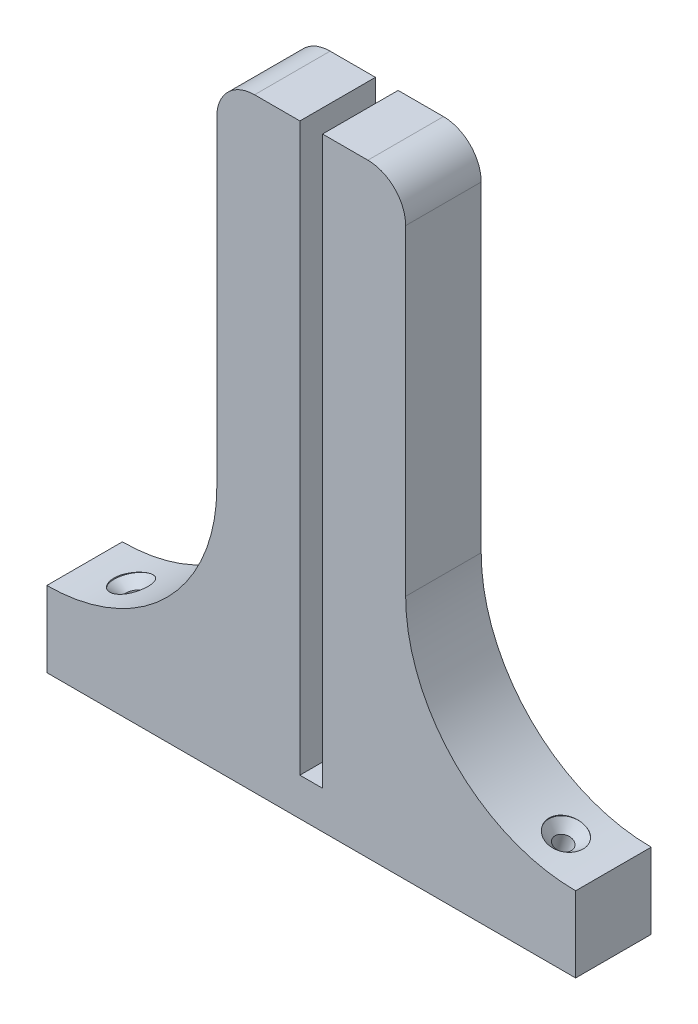
from build123d import *

# Parameters (mm, degrees)
BOSS_EXTRU_1_DEPTH                             = 20
CONG_1_R                                       = 10
ESQUISSE2_W                                    = 6
ESQUISSE2_H                                    = 150
ENL_V_MAT_EXTRU_1_DEPTH                        = 20
ENL_V_MAT_EXTRU_2_DEPTH                        = 0.6
FRAISAGE_POUR_VIS_T_TE_FRAIS_E_M41_D           = 4.5
FRAISAGE_POUR_VIS_T_TE_FRAIS_E_M41_CSINK_D     = 9.4
FRAISAGE_POUR_VIS_T_TE_FRAIS_E_M41_CSINK_ANGLE = 90


with BuildPart() as part:
    # Esquisse1 → Boss.-Extru.1 (new body)
    with BuildSketch(Plane.XY):
        with BuildLine():
            Line((-70, 0), (70, 0))
            Line((70, 0), (70, 20))
            ThreePointArc((70, 20), (38.180194847, 33.180194847), (25, 65))
            Line((25, 65), (25, 160))
            Line((25, 160), (-25, 160))
            Line((-25, 160), (-25, 65))
            ThreePointArc((-25, 65), (-38.180194847, 33.180194847), (-70, 20))
            Line((-70, 20), (-70, 0))
        make_face()
    extrude(amount=BOSS_EXTRU_1_DEPTH)

    # Congé1
    cong_1_edges = [part.edges().sort_by_distance(p)[0] for p in [
        (-25, 160, 10),
        (25, 160, 10),
    ]]
    fillet(cong_1_edges, radius=CONG_1_R)

    # Esquisse2 → Enlèv. mat.-Extru.1 (cut)
    with BuildSketch(Plane.XY.offset(20)):
        with Locations((0, 85)):
            Rectangle(ESQUISSE2_W, ESQUISSE2_H)
    extrude(amount=-ENL_V_MAT_EXTRU_1_DEPTH, mode=Mode.SUBTRACT)

    # Esquisse3 → Enlèv. mat.-Extru.2 (cut)
    with BuildSketch(Plane.ZY.offset(25)):
        with BuildLine():
            add(Edge.make_bspline(
                [(10.298264208, 116.00253619), (10.269097337, 115.992326869), (10.217774636, 115.974362311), (10.146223156, 115.960911494), (10.087850074, 115.966864128), (10.042769968, 115.997389601), (10.018320339, 116.051964444), (10.004954592, 116.125720815), (10.002334597, 116.224587194), (10.000840513, 116.299040881), (10, 116.340925628)],
                knots=[0, 0, 0, 0, 9.2636e-05, 0.000163005, 0.000217104, 0.000264221, 0.000318666, 0.000391065, 0.000488849, 0.000614604, 0.000614604, 0.000614604, 0.000614604], degree=3))
            add(Edge.make_bspline(
                [(10, 116.340925628), (10.000114375, 116.382830885), (10.000317702, 116.45732656), (10.004773603, 116.556579531), (10.01453085, 116.631507153), (10.02464009, 116.687809902), (10.043786522, 116.728119067), (10.070404737, 116.755826472), (10.102576181, 116.775404191), (10.125641709, 116.786940542), (10.137763289, 116.793003217)],
                knots=[0, 0, 0, 0, 0.000125733, 0.000223517, 0.000297674, 0.000352512, 0.000394382, 0.000429388, 0.000466115, 0.000506793, 0.000506793, 0.000506793, 0.000506793], degree=3))
            Line((10.137763289, 116.793003217), (11.540808824, 117.293231081))
            Line((11.540808824, 117.293231081), (11.540808824, 119.722144991))
            Line((11.540808824, 119.722144991), (10.156488396, 120.200972733))
            add(Edge.make_bspline(
                [(10.156488396, 120.200972733), (10.143862376, 120.205976287), (10.119506065, 120.215628427), (10.085507972, 120.235820612), (10.058092353, 120.265723983), (10.033968103, 120.305141208), (10.017547599, 120.359621157), (10.005565685, 120.430956204), (10.002174093, 120.522853414), (10.00077614, 120.591090262), (10, 120.628975184)],
                knots=[0, 0, 0, 0, 4.0745e-05, 7.8599e-05, 0.000117386, 0.000161199, 0.000216183, 0.000286768, 0.000377875, 0.000491595, 0.000491595, 0.000491595, 0.000491595], degree=3))
            add(Edge.make_bspline(
                [(10, 120.628975184), (10.000510946, 120.66864451), (10.00143085, 120.740064936), (10.007654826, 120.836367622), (10.023164734, 120.908664456), (10.048583816, 120.962231124), (10.093140982, 120.990826296), (10.15073614, 120.995142921), (10.221785969, 120.982308262), (10.273109429, 120.964251351), (10.302276731, 120.953989545)],
                knots=[0, 0, 0, 0, 0.000119068, 0.00021437, 0.000288659, 0.000340753, 0.000387124, 0.000439714, 0.000510082, 0.000602719, 0.000602719, 0.000602719, 0.000602719], degree=3))
            Line((10.302276731, 120.953989545), (15.665682445, 118.995878332))
            add(Edge.make_bspline(
                [(15.665682445, 118.995878332), (15.680224312, 118.989272066), (15.708098977, 118.976608806), (15.745112383, 118.949084074), (15.773356627, 118.910133289), (15.792627136, 118.858485618), (15.806954153, 118.793229828), (15.815447144, 118.711183525), (15.820619559, 118.609856356), (15.820757428, 118.53533922), (15.820833333, 118.49431296)],
                knots=[0, 0, 0, 0, 4.7852e-05, 9.1726e-05, 0.000136667, 0.000190067, 0.000255931, 0.000336726, 0.000437182, 0.00056024, 0.00056024, 0.00056024, 0.00056024], degree=3))
            add(Edge.make_bspline(
                [(15.820833333, 118.49431296), (15.820751345, 118.450170997), (15.820603023, 118.370316023), (15.815545051, 118.261812307), (15.806709356, 118.174582224), (15.793508021, 118.105178335), (15.771516131, 118.051537529), (15.742893381, 118.010273306), (15.7043801, 117.981144433), (15.675352025, 117.968518025), (15.660332414, 117.961984911)],
                knots=[0, 0, 0, 0, 0.00013242, 0.000239554, 0.000325665, 0.000395447, 0.000450594, 0.000498483, 0.000544233, 0.000593285, 0.000593285, 0.000593285, 0.000593285], degree=3))
            Line((15.660332414, 117.961984911), (10.298264208, 116.00253619))
        make_face()
        Polygon((15.050428922, 118.51705059), (15.050428922, 118.521063113), (12.140012255, 119.52820638), (12.140012255, 117.496532246), align=None, mode=Mode.SUBTRACT)
        with BuildLine():
            add(Edge.make_bspline(
                [(10.137763289, 114.305238971), (10.126952741, 114.306440051), (10.105807787, 114.308789312), (10.075590027, 114.322520282), (10.052152964, 114.34960007), (10.031346744, 114.386960575), (10.01867842, 114.439438389), (10.005169697, 114.506555801), (10.002316192, 114.59327153), (10.000826824, 114.657474067), (10, 114.693116192)],
                knots=[0, 0, 0, 0, 3.2543e-05, 6.3653e-05, 9.6768e-05, 0.000138079, 0.000190991, 0.000257625, 0.000343393, 0.000450427, 0.000450427, 0.000450427, 0.000450427], degree=3))
            add(Edge.make_bspline(
                [(10, 114.693116192), (10.000788929, 114.727430941), (10.002214206, 114.789423857), (10.005533098, 114.874244869), (10.018513727, 114.941543918), (10.031979891, 114.995265081), (10.050944416, 115.034754777), (10.075826673, 115.061160417), (10.105990396, 115.073434551), (10.12697314, 115.074893258), (10.137763289, 115.075643382)],
                knots=[0, 0, 0, 0, 0.000103023, 0.000186121, 0.000254071, 0.000308269, 0.000351938, 0.000384094, 0.000414652, 0.000447002, 0.000447002, 0.000447002, 0.000447002], degree=3))
            Line((10.137763289, 115.075643382), (14.142261221, 115.075643382))
            add(Edge.make_bspline(
                [(14.142261221, 115.075643382), (14.153100676, 115.074988992), (14.173768968, 115.073741223), (14.203196443, 115.060372601), (14.229274794, 115.035150123), (14.248947591, 114.995108055), (14.267208843, 114.942366519), (14.274209332, 114.873798524), (14.279977411, 114.789543787), (14.28000773, 114.727471176), (14.28002451, 114.693116192)],
                knots=[0, 0, 0, 0, 3.235e-05, 6.1684e-05, 9.4799e-05, 0.000139099, 0.000194083, 0.000261611, 0.000344708, 0.000447705, 0.000447705, 0.000447705, 0.000447705], degree=3))
            add(Edge.make_bspline(
                [(14.28002451, 114.693116192), (14.279987354, 114.657430062), (14.279920417, 114.593141559), (14.274485048, 114.507027011), (14.267034375, 114.438605055), (14.249618683, 114.387078279), (14.22805071, 114.349271182), (14.203376024, 114.323332935), (14.173976891, 114.30846141), (14.153126405, 114.306342917), (14.142261221, 114.305238971)],
                knots=[0, 0, 0, 0, 0.000107009, 0.000192776, 0.00025898, 0.000312697, 0.000354674, 0.000388722, 0.000418629, 0.000451172, 0.000451172, 0.000451172, 0.000451172], degree=3))
            Line((14.142261221, 114.305238971), (10.137763289, 114.305238971))
        make_face()
        with BuildLine():
            add(Edge.make_bspline(
                [(15.482443896, 114.904442402), (15.444864984, 114.90497412), (15.374947984, 114.905963402), (15.280152438, 114.925297195), (15.201582572, 114.951540877), (15.141020965, 114.995603849), (15.097897588, 115.056740729), (15.07119576, 115.13545123), (15.051978121, 115.230315707), (15.050970498, 115.300221823), (15.050428922, 115.337794884)],
                knots=[0, 0, 0, 0, 0.000112478, 0.00020927, 0.000289263, 0.000359083, 0.000429984, 0.000509977, 0.000606769, 0.000719247, 0.000719247, 0.000719247, 0.000719247], degree=3))
            add(Edge.make_bspline(
                [(15.050428922, 115.337794884), (15.051042843, 115.375350428), (15.052169349, 115.444262387), (15.07001531, 115.537842549), (15.095166142, 115.613961669), (15.135593008, 115.674019365), (15.195496519, 115.713766754), (15.270349855, 115.741646957), (15.363585716, 115.758385572), (15.431991775, 115.75972261), (15.469068819, 115.760447304)],
                knots=[0, 0, 0, 0, 0.000112478, 0.00020639, 0.000284665, 0.000351834, 0.000419003, 0.000496498, 0.00059041, 0.000701552, 0.000701552, 0.000701552, 0.000701552], degree=3))
            add(Edge.make_bspline(
                [(15.469068819, 115.760447304), (15.507481007, 115.759692066), (15.57853694, 115.758295007), (15.675854588, 115.741758824), (15.754269606, 115.713153879), (15.815387889, 115.671002169), (15.85937987, 115.611497135), (15.887461278, 115.534260122), (15.904379597, 115.439291858), (15.905712187, 115.369979507), (15.906433824, 115.332444853)],
                knots=[0, 0, 0, 0, 0.00011515, 0.000213008, 0.000294727, 0.000363761, 0.00043251, 0.000512983, 0.000608209, 0.000720687, 0.000720687, 0.000720687, 0.000720687], degree=3))
            add(Edge.make_bspline(
                [(15.906433824, 115.332444853), (15.905746572, 115.294903577), (15.904477479, 115.225578998), (15.887188017, 115.130845605), (15.86034961, 115.053432876), (15.818635727, 114.992794954), (15.758906922, 114.950494476), (15.68232171, 114.923479461), (15.588403853, 114.906519168), (15.519534335, 114.905169357), (15.482443896, 114.904442402)],
                knots=[0, 0, 0, 0, 0.000112478, 0.000207704, 0.000287698, 0.000356732, 0.000424682, 0.000503425, 0.000598651, 0.000709793, 0.000709793, 0.000709793, 0.000709793], degree=3))
        make_face()
        with BuildLine():
            add(Edge.make_bspline(
                [(15.482443896, 113.449234069), (15.444864984, 113.449765787), (15.374947984, 113.450755069), (15.280152438, 113.470088862), (15.201582572, 113.496332543), (15.141020965, 113.540395515), (15.097897588, 113.601532395), (15.07119576, 113.680242896), (15.051978121, 113.775107374), (15.050970498, 113.845013489), (15.050428922, 113.88258655)],
                knots=[0, 0, 0, 0, 0.000112478, 0.00020927, 0.000289263, 0.000359083, 0.000429984, 0.000509977, 0.000606769, 0.000719247, 0.000719247, 0.000719247, 0.000719247], degree=3))
            add(Edge.make_bspline(
                [(15.050428922, 113.88258655), (15.051042843, 113.920142095), (15.052169349, 113.989054054), (15.07001531, 114.082634216), (15.095166142, 114.158753336), (15.135593008, 114.218811032), (15.195496519, 114.258558421), (15.270349855, 114.286438624), (15.363585716, 114.303177238), (15.431991775, 114.304514277), (15.469068819, 114.305238971)],
                knots=[0, 0, 0, 0, 0.000112478, 0.00020639, 0.000284665, 0.000351834, 0.000419003, 0.000496498, 0.00059041, 0.000701552, 0.000701552, 0.000701552, 0.000701552], degree=3))
            add(Edge.make_bspline(
                [(15.469068819, 114.305238971), (15.507480723, 114.304483612), (15.578536131, 114.303086328), (15.675857083, 114.286551557), (15.75426241, 114.257942471), (15.815410243, 114.21580339), (15.85904033, 114.156589791), (15.887356633, 114.08087932), (15.904497657, 113.987675081), (15.905750426, 113.919679053), (15.906433824, 113.88258655)],
                knots=[0, 0, 0, 0, 0.00011515, 0.000213008, 0.000294727, 0.000363761, 0.00043251, 0.000511739, 0.000604337, 0.000715479, 0.000715479, 0.000715479, 0.000715479], degree=3))
            add(Edge.make_bspline(
                [(15.906433824, 113.88258655), (15.905777513, 113.844148176), (15.904570951, 113.773483077), (15.887088424, 113.67705046), (15.86068409, 113.598539584), (15.818612961, 113.537595226), (15.758914017, 113.495283461), (15.682319241, 113.468272061), (15.588404648, 113.451310534), (15.519534614, 113.449960919), (15.482443896, 113.449234069)],
                knots=[0, 0, 0, 0, 0.00011515, 0.000211692, 0.000292939, 0.000361973, 0.000429923, 0.000508666, 0.000603892, 0.000715034, 0.000715034, 0.000715034, 0.000715034], degree=3))
        make_face()
        with BuildLine():
            add(Edge.make_bspline(
                [(12.295163143, 109.426011029), (12.267907447, 109.426947638), (12.216857846, 109.428701896), (12.145758019, 109.443741511), (12.088029732, 109.472661135), (12.042032764, 109.510528174), (12.011185902, 109.557494869), (11.985689828, 109.60534849), (11.972530905, 109.657632034), (11.970060534, 109.693009755), (11.968811275, 109.710900161)],
                knots=[0, 0, 0, 0, 8.1763e-05, 0.000153142, 0.000215947, 0.000273832, 0.000329496, 0.000383329, 0.000435885, 0.000489652, 0.000489652, 0.000489652, 0.000489652], degree=3))
            Line((11.968811275, 109.710900161), (11.968811275, 112.336427696))
            add(Edge.make_bspline(
                [(11.968811275, 112.336427696), (11.914399597, 112.335675361), (11.808556941, 112.334211905), (11.653481631, 112.322310073), (11.507008251, 112.300871807), (11.368645965, 112.271985648), (11.239466638, 112.233398202), (11.119292521, 112.184116643), (11.009201712, 112.122029714), (10.908363832, 112.049779916), (10.817107913, 111.966109096), (10.738576645, 111.869012352), (10.669739472, 111.760988947), (10.611688096, 111.641502327), (10.567739016, 111.508291514), (10.535853566, 111.362218198), (10.517464709, 111.202241204), (10.514921785, 111.091255885), (10.513602941, 111.033695236)],
                knots=[0, 0, 0, 0, 0.000163225, 0.000317509, 0.000466183, 0.000607054, 0.000741185, 0.0008701, 0.000995855, 0.001119464, 0.001241558, 0.001366062, 0.001492956, 0.00162516, 0.001763467, 0.001912748, 0.002073009, 0.002245677, 0.002245677, 0.002245677, 0.002245677], degree=3))
            add(Edge.make_bspline(
                [(10.513602941, 111.033695236), (10.513800845, 110.987296925), (10.514183925, 110.897484363), (10.526135339, 110.766802361), (10.541089055, 110.643807458), (10.571341734, 110.494681598), (10.617109769, 110.327080018), (10.679127929, 110.149631539), (10.743769883, 110.003142849), (10.796377529, 109.884546936), (10.844080672, 109.795758508), (10.852556206, 109.740196061), (10.856004902, 109.717587699)],
                knots=[0, 0, 0, 0, 0.000139127, 0.000269305, 0.000393398, 0.00051065, 0.000725439, 0.000914109, 0.001074102, 0.001205164, 0.001304572, 0.001372772, 0.001372772, 0.001372772, 0.001372772], degree=3))
            add(Edge.make_bspline(
                [(10.856004902, 109.717587699), (10.85525752, 109.707644375), (10.853771909, 109.687879486), (10.841206037, 109.660963629), (10.821469304, 109.637618619), (10.791286215, 109.622066765), (10.752471041, 109.609904542), (10.702367706, 109.603044318), (10.640357119, 109.59729763), (10.594767264, 109.597242324), (10.569778263, 109.59721201)],
                knots=[0, 0, 0, 0, 2.9697e-05, 5.9031e-05, 8.7467e-05, 0.000119817, 0.000159154, 0.000209289, 0.000271046, 0.000345959, 0.000345959, 0.000345959, 0.000345959], degree=3))
            add(Edge.make_bspline(
                [(10.569778263, 109.59721201), (10.551946828, 109.597591463), (10.518492316, 109.598303375), (10.47152045, 109.600285917), (10.430548176, 109.606216175), (10.394179233, 109.612436835), (10.36157064, 109.621504073), (10.331991032, 109.635324997), (10.306175037, 109.654828734), (10.282092858, 109.672925032), (10.263408262, 109.697957154), (10.244853866, 109.729608512), (10.22161801, 109.773336712), (10.178353861, 109.851181111), (10.127168962, 109.976012971), (10.065204935, 110.152307677), (10.009219881, 110.363008798), (9.958570297, 110.602729633), (9.920487255, 110.866695606), (9.91646252, 111.050495646), (9.91439951, 111.144708372)],
                knots=[0, 0, 0, 0, 5.3517e-05, 0.000100406, 0.000140886, 0.000177613, 0.000211051, 0.000242161, 0.000274813, 0.000308036, 0.00033185, 0.000367863, 0.00041814, 0.000480374, 0.000634924, 0.000821888, 0.001040901, 0.001288267, 0.00155687, 0.001839341, 0.001839341, 0.001839341, 0.001839341], degree=3))
            add(Edge.make_bspline(
                [(9.91439951, 111.144708372), (9.91638233, 111.226347584), (9.92023875, 111.385129062), (9.944655805, 111.615454988), (9.989788218, 111.82949561), (10.048389302, 112.028955847), (10.12911499, 112.21185356), (10.222624563, 112.381602309), (10.337368019, 112.53369645), (10.465595834, 112.672861088), (10.612864486, 112.795181561), (10.777303394, 112.901331926), (10.959182186, 112.991053501), (11.158305419, 113.064462021), (11.374658359, 113.121723471), (11.608227466, 113.16246028), (11.858544913, 113.188537691), (12.031160515, 113.191109648), (12.11994964, 113.192432598)],
                knots=[0, 0, 0, 0, 0.000244943, 0.000476394, 0.000693589, 0.000900488, 0.001098769, 0.001292209, 0.001480532, 0.001668855, 0.001858771, 0.002053171, 0.002254748, 0.002465926, 0.002688813, 0.002925204, 0.003176606, 0.003442891, 0.003442891, 0.003442891, 0.003442891], degree=3))
            add(Edge.make_bspline(
                [(12.11994964, 113.192432598), (12.204727247, 113.191081829), (12.37022644, 113.188444915), (12.612156171, 113.162334556), (12.840943919, 113.120411618), (13.056162214, 113.059923826), (13.256361416, 112.983622524), (13.443411775, 112.894433583), (13.612747004, 112.787093882), (13.767028533, 112.666129303), (13.903758047, 112.530121507), (14.025498183, 112.381082084), (14.128228477, 112.217097921), (14.214099247, 112.0408566), (14.282949083, 111.853302294), (14.330244129, 111.653935337), (14.360943881, 111.444373846), (14.364043412, 111.300862803), (14.365625, 111.227633847)],
                knots=[0, 0, 0, 0, 0.000254253, 0.000496342, 0.000729026, 0.00095133, 0.001165953, 0.001371133, 0.001571889, 0.001766154, 0.001958146, 0.002149279, 0.002342237, 0.002537243, 0.002736531, 0.002940255, 0.00315097, 0.003370521, 0.003370521, 0.003370521, 0.003370521], degree=3))
            add(Edge.make_bspline(
                [(14.365625, 111.227633847), (14.36413248, 111.149942936), (14.361255734, 111.000198224), (14.330750997, 110.784800258), (14.284335776, 110.586701434), (14.214390198, 110.407787782), (14.131479226, 110.244328144), (14.033546255, 110.097075415), (13.922618452, 109.963993944), (13.798329619, 109.846265723), (13.660853272, 109.744369144), (13.512322767, 109.656821694), (13.352867777, 109.583223786), (13.18254065, 109.524345579), (13.003504556, 109.481518154), (12.818225456, 109.44875662), (12.626799801, 109.430159793), (12.497164695, 109.427404693), (12.431588925, 109.426011029)],
                knots=[0, 0, 0, 0, 0.000232915, 0.000448929, 0.000651353, 0.000841872, 0.001023719, 0.001200295, 0.001371203, 0.001542451, 0.001712583, 0.001883475, 0.002058816, 0.002238586, 0.002423166, 0.002610513, 0.002802691, 0.002999418, 0.002999418, 0.002999418, 0.002999418], degree=3))
            Line((12.431588925, 109.426011029), (12.295163143, 109.426011029))
        make_face()
        with BuildLine():
            add(Edge.make_bspline(
                [(12.482414216, 110.196415441), (12.531018437, 110.196304615), (12.625655426, 110.196088825), (12.763857224, 110.205028113), (12.894201906, 110.224340943), (13.01680672, 110.249670581), (13.130470878, 110.287036267), (13.236778829, 110.33035765), (13.334490566, 110.384510528), (13.425075572, 110.445615915), (13.504882091, 110.516765197), (13.575998123, 110.594940329), (13.634821343, 110.682615941), (13.682924577, 110.777981399), (13.721041532, 110.881102693), (13.747051665, 110.992072512), (13.763688977, 111.111215197), (13.765490234, 111.193245426), (13.766421569, 111.235658892)],
                knots=[0, 0, 0, 0, 0.000145794, 0.000283876, 0.000414958, 0.000540883, 0.000658895, 0.000773406, 0.000884741, 0.000993442, 0.001100518, 0.001204706, 0.00130969, 0.001416162, 0.001524492, 0.001638683, 0.001757473, 0.001884648, 0.001884648, 0.001884648, 0.001884648], degree=3))
            add(Edge.make_bspline(
                [(13.766421569, 111.235658892), (13.765198304, 111.27898316), (13.762813496, 111.363445694), (13.742546762, 111.485696501), (13.70876393, 111.599777618), (13.662171493, 111.705331458), (13.603182488, 111.801778684), (13.539042617, 111.892291699), (13.462134345, 111.971266878), (13.379437206, 112.043993531), (13.287924301, 112.108512814), (13.188323525, 112.164022393), (13.082645531, 112.214757632), (12.93017424, 112.266353778), (12.730771119, 112.318950187), (12.565736164, 112.330564118), (12.482414216, 112.336427696)],
                knots=[0, 0, 0, 0, 0.00012991, 0.000253266, 0.000370487, 0.000486056, 0.000598223, 0.000709244, 0.000818044, 0.000928013, 0.00103934, 0.001153146, 0.001269824, 0.001390385, 0.001635627, 0.001885698, 0.001885698, 0.001885698, 0.001885698], degree=3))
            Line((12.482414216, 112.336427696), (12.482414216, 110.196415441))
        make_face(mode=Mode.SUBTRACT)
        with BuildLine():
            add(Edge.make_bspline(
                [(10.345076976, 103.177175245), (10.317000076, 103.177956538), (10.26524768, 103.179396647), (10.193775132, 103.182931754), (10.134591551, 103.195525879), (10.085769193, 103.212028557), (10.047624521, 103.234975624), (10.01854723, 103.261914966), (10.003103851, 103.296652865), (10.001058104, 103.321046651), (10, 103.333663641)],
                knots=[0, 0, 0, 0, 8.4305e-05, 0.000155395, 0.000214154, 0.000265348, 0.00030916, 0.00034699, 0.000382301, 0.000420132, 0.000420132, 0.000420132, 0.000420132], degree=3))
            Line((10, 103.333663641), (10, 105.886965763))
            add(Edge.make_bspline(
                [(10, 105.886965763), (10.003536552, 105.92100722), (10.010796097, 105.990884735), (10.05650501, 106.070315548), (10.110312551, 106.124438375), (10.167185469, 106.153632745), (10.236145728, 106.171130851), (10.286104631, 106.172471361), (10.312976792, 106.173192402)],
                knots=[0, 0, 0, 0, 0.000101809, 0.000208985, 0.000266684, 0.000328918, 0.000398016, 0.000478445, 0.000478445, 0.000478445, 0.000478445], degree=3))
            Line((10.312976792, 106.173192402), (15.677720014, 106.173192402))
            add(Edge.make_bspline(
                [(15.677720014, 106.173192402), (15.689023202, 106.17209402), (15.711307587, 106.169928546), (15.742781873, 106.154303145), (15.768860774, 106.124764877), (15.784104611, 106.078986859), (15.79899446, 106.019613199), (15.809880164, 105.943369105), (15.820346784, 105.85023515), (15.820661732, 105.782238359), (15.820833333, 105.745189951)],
                knots=[0, 0, 0, 0, 3.3863e-05, 6.6761e-05, 0.00010275, 0.000148947, 0.000209609, 0.000286791, 0.000379553, 0.000490598, 0.000490598, 0.000490598, 0.000490598], degree=3))
            add(Edge.make_bspline(
                [(15.820833333, 105.745189951), (15.820642524, 105.707256606), (15.820293837, 105.637936914), (15.810280107, 105.544260201), (15.798759146, 105.469062327), (15.784401262, 105.411174422), (15.768039609, 105.366641961), (15.743291519, 105.336067331), (15.711257974, 105.320491248), (15.689006506, 105.318299307), (15.677720014, 105.3171875)],
                knots=[0, 0, 0, 0, 0.00011372, 0.000207812, 0.000282353, 0.000341718, 0.000386679, 0.000423673, 0.000456571, 0.000490434, 0.000490434, 0.000490434, 0.000490434], degree=3))
            Line((15.677720014, 105.3171875), (10.684803922, 105.3171875))
            Line((10.684803922, 105.3171875), (10.684803922, 103.326976103))
            add(Edge.make_bspline(
                [(10.684803922, 103.326976103), (10.683906626, 103.314703221), (10.682156495, 103.290765577), (10.664462281, 103.259065487), (10.638945237, 103.232111236), (10.602922544, 103.210734794), (10.55551668, 103.195231414), (10.496790857, 103.183056829), (10.42491444, 103.179362967), (10.373156749, 103.177944692), (10.345076976, 103.177175245)],
                knots=[0, 0, 0, 0, 3.6507e-05, 7.1205e-05, 0.000106211, 0.000147043, 0.000195268, 0.000255336, 0.000326426, 0.000410731, 0.000410731, 0.000410731, 0.000410731], degree=3))
        make_face()
        with BuildLine():
            add(Edge.make_bspline(
                [(10.133750766, 99.325153186), (10.117499868, 99.326553216), (10.086383753, 99.329233897), (10.049341677, 99.362577538), (10.028311647, 99.410039503), (10.00951912, 99.471876554), (10.002560398, 99.556885748), (10.000934697, 99.621209577), (10, 99.658192593)],
                knots=[0, 0, 0, 0, 4.774e-05, 9.1409e-05, 0.000141059, 0.000202424, 0.000284548, 0.000395633, 0.000395633, 0.000395633, 0.000395633], degree=3))
            add(Edge.make_bspline(
                [(10, 99.658192593), (10.000909497, 99.695183669), (10.00251313, 99.760406658), (10.009972006, 99.847514115), (10.027422764, 99.911366001), (10.049025137, 99.960014596), (10.08840417, 99.98930887), (10.1190282, 99.991447797), (10.135088274, 99.992569508)],
                knots=[0, 0, 0, 0, 0.000111086, 0.000195867, 0.00026109, 0.000309555, 0.000352626, 0.000400122, 0.000400122, 0.000400122, 0.000400122], degree=3))
            Line((10.135088274, 99.992569508), (10.541690602, 99.992569508))
            add(Edge.make_bspline(
                [(10.541690602, 99.992569508), (10.495897809, 100.036864691), (10.405072698, 100.124719452), (10.283271821, 100.268410027), (10.176159904, 100.419853721), (10.083267964, 100.577692324), (10.007380833, 100.742027054), (9.954065325, 100.912838845), (9.920375564, 101.088446581), (9.916401679, 101.207321408), (9.91439951, 101.267214308)],
                knots=[0, 0, 0, 0, 0.000191044, 0.000378915, 0.000564096, 0.000746924, 0.000927685, 0.001105775, 0.001282589, 0.001462134, 0.001462134, 0.001462134, 0.001462134], degree=3))
            add(Edge.make_bspline(
                [(9.91439951, 101.267214308), (9.915360016, 101.318979135), (9.917244433, 101.42053657), (9.933916385, 101.568434669), (9.958770938, 101.709057671), (9.995249389, 101.841306575), (10.039927583, 101.96633699), (10.09645303, 102.081049106), (10.160842186, 102.186722498), (10.234936635, 102.282172152), (10.317844947, 102.36849119), (10.411146874, 102.443202853), (10.51180144, 102.509751141), (10.622090958, 102.564181662), (10.740593243, 102.6089689), (10.867562616, 102.640722636), (11.002563505, 102.659637652), (11.094911125, 102.662239219), (11.142231541, 102.663572304)],
                knots=[0, 0, 0, 0, 0.000155243, 0.000304572, 0.000445975, 0.000583224, 0.000715664, 0.000843674, 0.000966171, 0.001086294, 0.001205475, 0.001324333, 0.001444157, 0.001566778, 0.001692483, 0.001823538, 0.001958593, 0.002100527, 0.002100527, 0.002100527, 0.002100527], degree=3))
            add(Edge.make_bspline(
                [(11.142231541, 102.663572304), (11.197204299, 102.66238753), (11.304283877, 102.660079749), (11.458546266, 102.631913965), (11.602736212, 102.59017851), (11.734051929, 102.527179742), (11.856033261, 102.450861886), (11.966095099, 102.3574877), (12.065692549, 102.249638577), (12.154393656, 102.126946676), (12.23163765, 101.989188214), (12.300525564, 101.837909522), (12.355589863, 101.670679666), (12.402482611, 101.490698724), (12.437835007, 101.297031902), (12.465038532, 101.091776165), (12.479053921, 100.874183248), (12.481274858, 100.72554055), (12.482414216, 100.649285769)],
                knots=[0, 0, 0, 0, 0.000164709, 0.000320831, 0.000468927, 0.000613724, 0.000756211, 0.000899549, 0.001045307, 0.001195662, 0.001352601, 0.00151842, 0.001693526, 0.001880059, 0.002076016, 0.002283722, 0.002500898, 0.002729674, 0.002729674, 0.002729674, 0.002729674], degree=3))
            Line((12.482414216, 100.649285769), (12.482414216, 100.095557598))
            Line((12.482414216, 100.095557598), (12.800741039, 100.095557598))
            add(Edge.make_bspline(
                [(12.800741039, 100.095557598), (12.875415585, 100.097319938), (13.016467878, 100.10064881), (13.18557477, 100.134073572), (13.30698104, 100.170050909), (13.385927587, 100.20939981), (13.459778752, 100.251134174), (13.524264189, 100.304094664), (13.580349059, 100.365088831), (13.631293901, 100.432366258), (13.671574311, 100.509328771), (13.707834303, 100.593370663), (13.73327889, 100.68762342), (13.754253241, 100.791128017), (13.763786637, 100.905021202), (13.765521508, 100.984099258), (13.766421569, 101.025125421)],
                knots=[0, 0, 0, 0, 0.000223688, 0.000422523, 0.000515159, 0.000602508, 0.000686462, 0.000769182, 0.000851513, 0.000934707, 0.001021491, 0.001111413, 0.001208785, 0.001313709, 0.001427899, 0.001551015, 0.001551015, 0.001551015, 0.001551015], degree=3))
            add(Edge.make_bspline(
                [(13.766421569, 101.025125421), (13.765663343, 101.069734641), (13.764181904, 101.156893229), (13.752271143, 101.284380474), (13.731177843, 101.404733502), (13.691436583, 101.5514648), (13.636050132, 101.718685705), (13.556696724, 101.895835407), (13.482431302, 102.047645139), (13.419526462, 102.154560643), (13.376117406, 102.226595203), (13.357235982, 102.272590708), (13.34124856, 102.309889731), (13.339281268, 102.333542384), (13.338419118, 102.343907973)],
                knots=[0, 0, 0, 0, 0.000133811, 0.000261443, 0.000383706, 0.000499846, 0.000717248, 0.000911316, 0.001081789, 0.001223798, 0.001283688, 0.001333392, 0.001373159, 0.001404182, 0.001404182, 0.001404182, 0.001404182], degree=3))
            add(Edge.make_bspline(
                [(13.338419118, 102.343907973), (13.339605797, 102.35517395), (13.341925165, 102.377193338), (13.355925818, 102.408754956), (13.381429227, 102.433958361), (13.4154436, 102.456133285), (13.459009408, 102.474980387), (13.5138067, 102.483905141), (13.57586596, 102.490807356), (13.620159541, 102.491833559), (13.643370864, 102.492371324)],
                knots=[0, 0, 0, 0, 3.3863e-05, 6.6185e-05, 0.000101191, 0.000139771, 0.000187716, 0.000242276, 0.000305494, 0.000375096, 0.000375096, 0.000375096, 0.000375096], degree=3))
            add(Edge.make_bspline(
                [(13.643370864, 102.492371324), (13.678619999, 102.491700383), (13.741361652, 102.490506142), (13.828157635, 102.480045087), (13.903493282, 102.452401165), (13.954888143, 102.407163992), (13.997022102, 102.361116258), (14.027831305, 102.31151224), (14.063206547, 102.253464592), (14.109997414, 102.15664055), (14.17015264, 102.019646647), (14.22961154, 101.834543825), (14.285331192, 101.630530488), (14.327554847, 101.409672397), (14.361223841, 101.179035744), (14.364156208, 101.022129933), (14.365625, 100.943537454)],
                knots=[0, 0, 0, 0, 0.000105739, 0.00018821, 0.000261481, 0.00034232, 0.000390637, 0.000448507, 0.000516864, 0.000594623, 0.000770774, 0.000965334, 0.001177193, 0.001404876, 0.001639626, 0.001875214, 0.001875214, 0.001875214, 0.001875214], degree=3))
            add(Edge.make_bspline(
                [(14.365625, 100.943537454), (14.364124889, 100.872628844), (14.361233157, 100.735939879), (14.345286742, 100.538465714), (14.312473984, 100.358059004), (14.27063192, 100.193377129), (14.215342529, 100.045225642), (14.149635664, 99.911308844), (14.072622803, 99.791284188), (13.98135944, 99.687678056), (13.880843409, 99.596355169), (13.766052947, 99.521766878), (13.642201895, 99.456678172), (13.505066787, 99.407655671), (13.357541989, 99.370718206), (13.1983325, 99.344048681), (13.027555782, 99.328038598), (12.909560532, 99.326132987), (12.848891314, 99.325153186)],
                knots=[0, 0, 0, 0, 0.000212769, 0.00041015, 0.000593544, 0.00076224, 0.000919254, 0.001066998, 0.001209083, 0.0013456, 0.001480111, 0.00161514, 0.001755119, 0.001898987, 0.002050804, 0.002210881, 0.002382833, 0.002564812, 0.002564812, 0.002564812, 0.002564812], degree=3))
            Line((12.848891314, 99.325153186), (10.133750766, 99.325153186))
        make_face()
        with BuildLine():
            Line((11.968811275, 100.095557598), (11.968811275, 100.720173675))
            add(Edge.make_bspline(
                [(11.968811275, 100.720173675), (11.968615955, 100.768799729), (11.968239116, 100.862616467), (11.956412711, 100.998215786), (11.941498208, 101.12390065), (11.918280216, 101.239471808), (11.890531357, 101.346070197), (11.8563154, 101.443481175), (11.814772465, 101.531495295), (11.766172214, 101.608773592), (11.714174134, 101.678521548), (11.655280176, 101.737047841), (11.591580081, 101.786366968), (11.522630461, 101.824722362), (11.449539645, 101.856805981), (11.37044205, 101.87700566), (11.286323775, 101.891539898), (11.228347295, 101.892613473), (11.198406863, 101.893167892)],
                knots=[0, 0, 0, 0, 0.000145813, 0.000281324, 0.00040807, 0.000525322, 0.000634654, 0.0007383, 0.000834619, 0.000925923, 0.001011795, 0.001095022, 0.001174207, 0.001252676, 0.00133118, 0.001412943, 0.00149694, 0.001586643, 0.001586643, 0.001586643, 0.001586643], degree=3))
            add(Edge.make_bspline(
                [(11.198406863, 101.893167892), (11.148627944, 101.891240026), (11.052860972, 101.887531109), (10.917439681, 101.848228123), (10.796690262, 101.786846826), (10.69561774, 101.697490332), (10.612577254, 101.588543766), (10.554902264, 101.457500265), (10.519804812, 101.307830975), (10.515740108, 101.201440025), (10.513602941, 101.145501111)],
                knots=[0, 0, 0, 0, 0.000148951, 0.000286558, 0.000419369, 0.000552113, 0.000687737, 0.00082721, 0.00097839, 0.001146011, 0.001146011, 0.001146011, 0.001146011], degree=3))
            add(Edge.make_bspline(
                [(10.513602941, 101.145501111), (10.515324173, 101.09808946), (10.518732747, 101.004199633), (10.548407748, 100.866702553), (10.593677872, 100.734166681), (10.659601984, 100.606231525), (10.746077428, 100.481346315), (10.849606636, 100.353716995), (10.973603041, 100.223754867), (11.065895166, 100.139568673), (11.11414388, 100.095557598)],
                knots=[0, 0, 0, 0, 0.000142085, 0.000281372, 0.000420112, 0.000561281, 0.000711523, 0.000875082, 0.001053893, 0.001249778, 0.001249778, 0.001249778, 0.001249778], degree=3))
            Line((11.11414388, 100.095557598), (11.968811275, 100.095557598))
        make_face(mode=Mode.SUBTRACT)
        with BuildLine():
            add(Edge.make_bspline(
                [(12.192175054, 94.189123775), (12.106504526, 94.190024141), (11.939299627, 94.191781405), (11.695235445, 94.21663076), (11.463666633, 94.249093255), (11.246574435, 94.300681092), (11.043904911, 94.364650584), (10.85551554, 94.441387981), (10.684040946, 94.534953727), (10.525776369, 94.638165055), (10.386650046, 94.758710546), (10.262336746, 94.889392984), (10.157217146, 95.034716803), (10.068653779, 95.191423889), (9.99762687, 95.361212693), (9.951673147, 95.544406535), (9.918480966, 95.738099955), (9.915782065, 95.871556187), (9.91439951, 95.939921301)],
                knots=[0, 0, 0, 0, 0.000256889, 0.000501375, 0.000735362, 0.000957919, 0.001169842, 0.001372526, 0.001567017, 0.001755093, 0.001938175, 0.002117959, 0.002295061, 0.002474731, 0.002657045, 0.002845211, 0.003040253, 0.003245106, 0.003245106, 0.003245106, 0.003245106], degree=3))
            add(Edge.make_bspline(
                [(9.91439951, 95.939921301), (9.9160724, 96.002444642), (9.919293303, 96.122824129), (9.947834305, 96.298878511), (9.999334678, 96.465323305), (10.074754576, 96.626493986), (10.172321736, 96.785222697), (10.293835253, 96.944606192), (10.439994473, 97.108704291), (10.549493716, 97.216552305), (10.607228477, 97.273416437)],
                knots=[0, 0, 0, 0, 0.000187485, 0.000360975, 0.00053316, 0.000708501, 0.000893387, 0.001091072, 0.001308999, 0.001552062, 0.001552062, 0.001552062, 0.001552062], degree=3))
            Line((10.607228477, 97.273416437), (10.133750766, 97.273416437))
            add(Edge.make_bspline(
                [(10.133750766, 97.273416437), (10.122960538, 97.274683792), (10.101453237, 97.277209911), (10.070589317, 97.290315299), (10.046513764, 97.317199727), (10.029795048, 97.355089748), (10.017644381, 97.403144742), (10.005860277, 97.462393319), (10.002127636, 97.535538203), (10.000754468, 97.589077162), (10, 97.618493413)],
                knots=[0, 0, 0, 0, 3.2543e-05, 6.4865e-05, 9.798e-05, 0.000138061, 0.000188034, 0.000246534, 0.000318957, 0.000407273, 0.000407273, 0.000407273, 0.000407273], degree=3))
            add(Edge.make_bspline(
                [(10, 97.618493413), (10.000701821, 97.647480449), (10.001988015, 97.700603576), (10.006413978, 97.773992284), (10.016516995, 97.834332911), (10.031719659, 97.88207877), (10.047858249, 97.920049973), (10.075389309, 97.942519551), (10.106222718, 97.953063794), (10.127878484, 97.954698313), (10.139100797, 97.955545343)],
                knots=[0, 0, 0, 0, 8.6979e-05, 0.000159402, 0.000220534, 0.000269604, 0.000310283, 0.000341622, 0.000372932, 0.00040661, 0.00040661, 0.00040661, 0.00040661], degree=3))
            Line((10.139100797, 97.955545343), (16.105722465, 97.955545343))
            add(Edge.make_bspline(
                [(16.105722465, 97.955545343), (16.11696024, 97.954795268), (16.13880666, 97.953337109), (16.170134614, 97.94111261), (16.19676647, 97.915228326), (16.215031061, 97.874836456), (16.231340658, 97.821918011), (16.240773574, 97.753835535), (16.247498188, 97.669462522), (16.248359354, 97.607370107), (16.248835784, 97.573018153)],
                knots=[0, 0, 0, 0, 3.3678e-05, 6.547e-05, 9.8585e-05, 0.000142254, 0.00019683, 0.000264556, 0.000347751, 0.000450774, 0.000450774, 0.000450774, 0.000450774], degree=3))
            add(Edge.make_bspline(
                [(16.248835784, 97.573018153), (16.248333718, 97.537336755), (16.2474289, 97.473032203), (16.241109562, 97.386780618), (16.231165352, 97.318861476), (16.215691421, 97.267182811), (16.195544646, 97.228968727), (16.1703775, 97.202358281), (16.138980193, 97.188687451), (16.116979087, 97.186341309), (16.105722465, 97.185140931)],
                knots=[0, 0, 0, 0, 0.000107034, 0.000192895, 0.000259301, 0.0003126, 0.000353912, 0.000387959, 0.000420281, 0.000454144, 0.000454144, 0.000454144, 0.000454144], degree=3))
            Line((16.105722465, 97.185140931), (13.699546186, 97.185140931))
            add(Edge.make_bspline(
                [(13.699546186, 97.185140931), (13.757170621, 97.126770918), (13.866915238, 97.015606362), (14.008631861, 96.841748028), (14.123170808, 96.671970515), (14.215595437, 96.506842061), (14.285414026, 96.342869339), (14.332595874, 96.177975241), (14.360311838, 96.008190089), (14.36382405, 95.893214176), (14.365625, 95.834258195)],
                knots=[0, 0, 0, 0, 0.000245963, 0.000468432, 0.00067172, 0.000859701, 0.001035327, 0.001205085, 0.00137308, 0.001549879, 0.001549879, 0.001549879, 0.001549879], degree=3))
            add(Edge.make_bspline(
                [(14.365625, 95.834258195), (14.363813231, 95.763228349), (14.360293306, 95.625230756), (14.326231114, 95.426624907), (14.271431967, 95.243517163), (14.194903369, 95.076697453), (14.09867956, 94.926478535), (13.988574504, 94.789764333), (13.861865963, 94.668890249), (13.720250817, 94.563177997), (13.566238483, 94.47050223), (13.398510721, 94.393117995), (13.21884135, 94.327225899), (13.02709211, 94.275934829), (12.826601143, 94.237991231), (12.619905965, 94.209924945), (12.40783776, 94.191813379), (12.264437024, 94.190024979), (12.192175054, 94.189123775)],
                knots=[0, 0, 0, 0, 0.000212933, 0.000413688, 0.000602395, 0.00078493, 0.000962294, 0.001136299, 0.00131036, 0.001486109, 0.001665484, 0.001848581, 0.002039414, 0.002238954, 0.002443295, 0.002651178, 0.002864551, 0.003081293, 0.003081293, 0.003081293, 0.003081293], degree=3))
        make_face()
        with BuildLine():
            add(Edge.make_bspline(
                [(12.105237056, 95.045128676), (12.210067441, 95.047747441), (12.416697144, 95.05290925), (12.671956552, 95.079442336), (12.86732836, 95.116689952), (13.005101204, 95.152481366), (13.133937696, 95.196605239), (13.253825938, 95.248571044), (13.363934073, 95.309959319), (13.463112854, 95.380833255), (13.55155403, 95.460748931), (13.628471581, 95.550200201), (13.690858142, 95.65132908), (13.735793624, 95.764289049), (13.76082613, 95.889345396), (13.764510485, 95.976369602), (13.766421569, 96.021509268)],
                knots=[0, 0, 0, 0, 0.000314545, 0.000619995, 0.000768464, 0.000910882, 0.001046657, 0.001176623, 0.001302377, 0.001424119, 0.001541531, 0.001659186, 0.001776864, 0.00189633, 0.002021977, 0.002157389, 0.002157389, 0.002157389, 0.002157389], degree=3))
            add(Edge.make_bspline(
                [(13.766421569, 96.021509268), (13.764339468, 96.067616938), (13.760145534, 96.160490701), (13.725980264, 96.299523663), (13.669520737, 96.43997364), (13.580584932, 96.579756398), (13.465714573, 96.723076082), (13.34953029, 96.842830871), (13.241284675, 96.941431188), (13.149601331, 97.022138568), (13.045946906, 97.103534338), (12.972550875, 97.157274364), (12.934491805, 97.185140931)],
                knots=[0, 0, 0, 0, 0.000138178, 0.00027833, 0.000427106, 0.000590435, 0.000773209, 0.000977529, 0.001090174, 0.001212473, 0.001343863, 0.001485373, 0.001485373, 0.001485373, 0.001485373], degree=3))
            Line((12.934491805, 97.185140931), (11.318782552, 97.185140931))
            add(Edge.make_bspline(
                [(11.318782552, 97.185140931), (11.256763374, 97.136710881), (11.137979821, 97.043954196), (10.975305507, 96.901169232), (10.836790624, 96.760267382), (10.720329975, 96.623026183), (10.627583067, 96.484951415), (10.563201053, 96.343543563), (10.521495907, 96.199072114), (10.516230428, 96.101140203), (10.513602941, 96.052271944)],
                knots=[0, 0, 0, 0, 0.000236039, 0.000452078, 0.000648806, 0.000828276, 0.000991501, 0.001145918, 0.001292904, 0.001439305, 0.001439305, 0.001439305, 0.001439305], degree=3))
            add(Edge.make_bspline(
                [(10.513602941, 96.052271944), (10.514755542, 96.008407452), (10.516990447, 95.923353693), (10.545464941, 95.801414402), (10.587767744, 95.688492445), (10.649292413, 95.586384867), (10.724162648, 95.493667589), (10.813083213, 95.412720075), (10.908774891, 95.336021693), (11.018445965, 95.272975668), (11.135814091, 95.217209342), (11.260687821, 95.168264473), (11.393225651, 95.13075838), (11.57776391, 95.087377675), (11.815974696, 95.052857832), (12.008816613, 95.047705053), (12.105237056, 95.045128676)],
                knots=[0, 0, 0, 0, 0.000131321, 0.000254633, 0.000373611, 0.000491744, 0.000610602, 0.000729828, 0.000851827, 0.000977759, 0.001108178, 0.001241561, 0.001379538, 0.001520992, 0.001810206, 0.002099417, 0.002099417, 0.002099417, 0.002099417], degree=3))
        make_face(mode=Mode.SUBTRACT)
    extrude(amount=-ENL_V_MAT_EXTRU_2_DEPTH, mode=Mode.SUBTRACT)

    # Fraisage pour vis à tête fraisée M41 (through all)
    with Locations(Plane(origin=(57.530456956, 21.762163603, 10.129789036), x_dir=(0.960840809, -0.277100957, 0), z_dir=(0.277100957, 0.960840809, 0))):
        with Locations((0, 0)):
            fraisage_pour_vis_t_te_frais_e_m41 = CounterSinkHole(FRAISAGE_POUR_VIS_T_TE_FRAIS_E_M41_D / 2, FRAISAGE_POUR_VIS_T_TE_FRAIS_E_M41_CSINK_D / 2, counter_sink_angle=FRAISAGE_POUR_VIS_T_TE_FRAIS_E_M41_CSINK_ANGLE)

    # Symétrie1: Fraisage pour vis à tête fraisée M41 across plane
    add(fraisage_pour_vis_t_te_frais_e_m41.mirror(Plane(origin=(0, 0, 0), x_dir=(0, 0, 1), z_dir=(1, 0, 0))), mode=Mode.SUBTRACT)


solid = part.part
